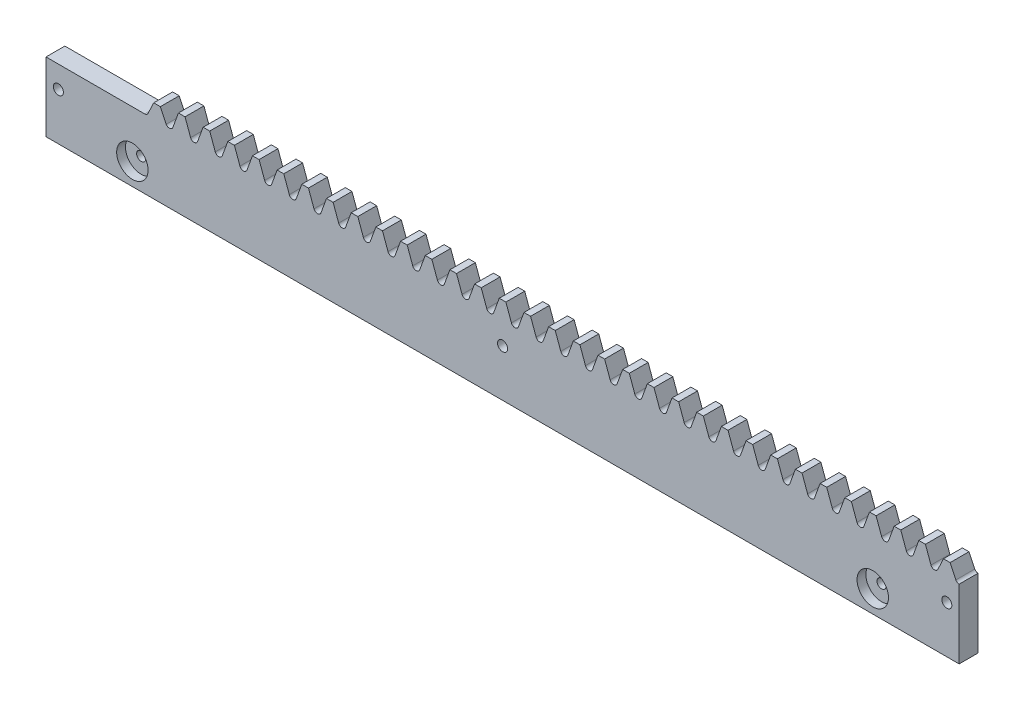
from build123d import *

# Parameters (mm, degrees)
ESQUISSE1_R             = 1.6
EXTRUSION1_DEPTH        = 6
ESQUISSE4_R             = 5
ENL_V_MAT_EXTRU_2_DEPTH = 2.8
ESQUISSE5_R             = 1.45
ENL_V_MAT_EXTRU_3_DEPTH = 2.5


with BuildPart() as part:
    # Esquisse1 → Extrusion1 (new body)
    with BuildSketch(Plane.XY):
        with BuildLine():
            Line((-11.780972452, 22), (19.634954087, 22))
            ThreePointArc((19.634954087, 22), (20.207764851, 22.148388876), (20.636482657, 22.556227657))
            Line((20.636482657, 22.556227657), (22.508375082, 26.5))
            Line((22.508375082, 26.5), (24.615514728, 26.5))
            Line((24.615514728, 26.5), (26.487407153, 22.556227657))
            ThreePointArc((26.487407153, 22.556227657), (26.916124959, 22.148388876), (27.488935722, 22))
            ThreePointArc((27.488935722, 22), (28.165627746, 22.213360175), (28.597563031, 22.776269199))
            Line((28.597563031, 22.776269199), (30.362356717, 27.625))
            Line((30.362356717, 27.625), (32.469496363, 27.625))
            Line((32.469496363, 27.625), (34.234290049, 22.776269199))
            ThreePointArc((34.234290049, 22.776269199), (34.666225334, 22.213360175), (35.342917357, 22))
            ThreePointArc((35.342917357, 22), (36.019609381, 22.213360175), (36.451544666, 22.776269199))
            Line((36.451544666, 22.776269199), (38.216338352, 27.625))
            Line((38.216338352, 27.625), (40.323477998, 27.625))
            Line((40.323477998, 27.625), (42.088271684, 22.776269199))
            ThreePointArc((42.088271684, 22.776269199), (42.520206969, 22.213360175), (43.196898992, 22))
            ThreePointArc((43.196898992, 22), (43.873591016, 22.213360175), (44.305526301, 22.776269199))
            Line((44.305526301, 22.776269199), (46.070319987, 27.625))
            Line((46.070319987, 27.625), (48.177459633, 27.625))
            Line((48.177459633, 27.625), (49.942253319, 22.776269199))
            ThreePointArc((49.942253319, 22.776269199), (50.374188604, 22.213360175), (51.050880627, 22))
            ThreePointArc((51.050880627, 22), (51.727572651, 22.213360175), (52.159507936, 22.776269199))
            Line((52.159507936, 22.776269199), (53.924301622, 27.625))
            Line((53.924301622, 27.625), (56.031441268, 27.625))
            Line((56.031441268, 27.625), (57.796234954, 22.776269199))
            ThreePointArc((57.796234954, 22.776269199), (58.228170239, 22.213360175), (58.904862262, 22))
            ThreePointArc((58.904862262, 22), (59.581554286, 22.213360175), (60.013489571, 22.776269199))
            Line((60.013489571, 22.776269199), (61.778283257, 27.625))
            Line((61.778283257, 27.625), (63.885422903, 27.625))
            Line((63.885422903, 27.625), (65.650216589, 22.776269199))
            ThreePointArc((65.650216589, 22.776269199), (66.082151874, 22.213360175), (66.758843897, 22))
            ThreePointArc((66.758843897, 22), (67.435535921, 22.213360175), (67.867471206, 22.776269199))
            Line((67.867471206, 22.776269199), (69.632264892, 27.625))
            Line((69.632264892, 27.625), (71.739404538, 27.625))
            Line((71.739404538, 27.625), (73.504198224, 22.776269199))
            ThreePointArc((73.504198224, 22.776269199), (73.936133509, 22.213360175), (74.612825532, 22))
            ThreePointArc((74.612825532, 22), (75.289517556, 22.213360175), (75.721452841, 22.776269199))
            Line((75.721452841, 22.776269199), (77.486246527, 27.625))
            Line((77.486246527, 27.625), (79.593386173, 27.625))
            Line((79.593386173, 27.625), (81.358179859, 22.776269199))
            ThreePointArc((81.358179859, 22.776269199), (81.790115144, 22.213360175), (82.466807167, 22))
            ThreePointArc((82.466807167, 22), (83.143499191, 22.213360175), (83.575434476, 22.776269199))
            Line((83.575434476, 22.776269199), (85.340228162, 27.625))
            Line((85.340228162, 27.625), (87.447367808, 27.625))
            Line((87.447367808, 27.625), (89.212161494, 22.776269199))
            ThreePointArc((89.212161494, 22.776269199), (89.644096779, 22.213360175), (90.320788802, 22))
            ThreePointArc((90.320788802, 22), (90.997480826, 22.213360175), (91.429416111, 22.776269199))
            Line((91.429416111, 22.776269199), (93.194209797, 27.625))
            Line((93.194209797, 27.625), (95.301349443, 27.625))
            Line((95.301349443, 27.625), (97.066143129, 22.776269199))
            ThreePointArc((97.066143129, 22.776269199), (97.498078414, 22.213360175), (98.174770437, 22))
            ThreePointArc((98.174770437, 22), (98.851462461, 22.213360175), (99.283397746, 22.776269199))
            Line((99.283397746, 22.776269199), (101.048191432, 27.625))
            Line((101.048191432, 27.625), (103.155331078, 27.625))
            Line((103.155331078, 27.625), (104.920124764, 22.776269199))
            ThreePointArc((104.920124764, 22.776269199), (105.352060049, 22.213360175), (106.028752072, 22))
            ThreePointArc((106.028752072, 22), (106.705444096, 22.213360175), (107.137379381, 22.776269199))
            Line((107.137379381, 22.776269199), (108.902173067, 27.625))
            Line((108.902173067, 27.625), (111.009312713, 27.625))
            Line((111.009312713, 27.625), (112.774106399, 22.776269199))
            ThreePointArc((112.774106399, 22.776269199), (113.206041684, 22.213360175), (113.882733707, 22))
            ThreePointArc((113.882733707, 22), (114.559425731, 22.213360175), (114.991361016, 22.776269199))
            Line((114.991361016, 22.776269199), (116.756154702, 27.625))
            Line((116.756154702, 27.625), (118.863294348, 27.625))
            Line((118.863294348, 27.625), (120.628088034, 22.776269199))
            ThreePointArc((120.628088034, 22.776269199), (121.060023319, 22.213360175), (121.736715342, 22))
            ThreePointArc((121.736715342, 22), (122.413407366, 22.213360175), (122.845342651, 22.776269199))
            Line((122.845342651, 22.776269199), (124.610136337, 27.625))
            Line((124.610136337, 27.625), (126.717275983, 27.625))
            Line((126.717275983, 27.625), (128.482069669, 22.776269199))
            ThreePointArc((128.482069669, 22.776269199), (128.914004954, 22.213360175), (129.590696977, 22))
            ThreePointArc((129.590696977, 22), (130.267389001, 22.213360175), (130.699324286, 22.776269199))
            Line((130.699324286, 22.776269199), (132.464117972, 27.625))
            Line((132.464117972, 27.625), (134.571257618, 27.625))
            Line((134.571257618, 27.625), (136.336051304, 22.776269199))
            ThreePointArc((136.336051304, 22.776269199), (136.767986589, 22.213360175), (137.444678612, 22))
            ThreePointArc((137.444678612, 22), (138.121370636, 22.213360175), (138.553305921, 22.776269199))
            Line((138.553305921, 22.776269199), (140.318099607, 27.625))
            Line((140.318099607, 27.625), (142.425239253, 27.625))
            Line((142.425239253, 27.625), (144.190032939, 22.776269199))
            ThreePointArc((144.190032939, 22.776269199), (144.621968224, 22.213360175), (145.298660247, 22))
            ThreePointArc((145.298660247, 22), (145.975352271, 22.213360175), (146.407287556, 22.776269199))
            Line((146.407287556, 22.776269199), (148.172081242, 27.625))
            Line((148.172081242, 27.625), (150.279220888, 27.625))
            Line((150.279220888, 27.625), (152.044014574, 22.776269199))
            ThreePointArc((152.044014574, 22.776269199), (152.475949859, 22.213360175), (153.152641882, 22))
            ThreePointArc((153.152641882, 22), (153.829333906, 22.213360175), (154.261269191, 22.776269199))
            Line((154.261269191, 22.776269199), (156.026062877, 27.625))
            Line((156.026062877, 27.625), (158.133202523, 27.625))
            Line((158.133202523, 27.625), (159.897996209, 22.776269199))
            ThreePointArc((159.897996209, 22.776269199), (160.329931494, 22.213360175), (161.006623517, 22))
            ThreePointArc((161.006623517, 22), (161.683315541, 22.213360175), (162.115250826, 22.776269199))
            Line((162.115250826, 22.776269199), (163.880044512, 27.625))
            Line((163.880044512, 27.625), (165.987184158, 27.625))
            Line((165.987184158, 27.625), (167.751977844, 22.776269199))
            ThreePointArc((167.751977844, 22.776269199), (168.183913129, 22.213360175), (168.860605152, 22))
            ThreePointArc((168.860605152, 22), (169.537297176, 22.213360175), (169.969232461, 22.776269199))
            Line((169.969232461, 22.776269199), (171.734026147, 27.625))
            Line((171.734026147, 27.625), (173.841165793, 27.625))
            Line((173.841165793, 27.625), (175.605959479, 22.776269199))
            ThreePointArc((175.605959479, 22.776269199), (176.037894764, 22.213360175), (176.714586787, 22))
            ThreePointArc((176.714586787, 22), (177.391278811, 22.213360175), (177.823214096, 22.776269199))
            Line((177.823214096, 22.776269199), (179.588007782, 27.625))
            Line((179.588007782, 27.625), (181.695147428, 27.625))
            Line((181.695147428, 27.625), (183.459941114, 22.776269199))
            ThreePointArc((183.459941114, 22.776269199), (183.891876399, 22.213360175), (184.568568422, 22))
            ThreePointArc((184.568568422, 22), (185.245260446, 22.213360175), (185.677195731, 22.776269199))
            Line((185.677195731, 22.776269199), (187.441989417, 27.625))
            Line((187.441989417, 27.625), (189.549129063, 27.625))
            Line((189.549129063, 27.625), (191.313922749, 22.776269199))
            ThreePointArc((191.313922749, 22.776269199), (191.745858034, 22.213360175), (192.422550057, 22))
            ThreePointArc((192.422550057, 22), (193.099242081, 22.213360175), (193.531177366, 22.776269199))
            Line((193.531177366, 22.776269199), (195.295971052, 27.625))
            Line((195.295971052, 27.625), (197.403110698, 27.625))
            Line((197.403110698, 27.625), (199.167904384, 22.776269199))
            ThreePointArc((199.167904384, 22.776269199), (199.599839669, 22.213360175), (200.276531692, 22))
            ThreePointArc((200.276531692, 22), (200.953223716, 22.213360175), (201.385159001, 22.776269199))
            Line((201.385159001, 22.776269199), (203.149952687, 27.625))
            Line((203.149952687, 27.625), (205.257092333, 27.625))
            Line((205.257092333, 27.625), (207.021886019, 22.776269199))
            ThreePointArc((207.021886019, 22.776269199), (207.453821304, 22.213360175), (208.130513327, 22))
            ThreePointArc((208.130513327, 22), (208.807205351, 22.213360175), (209.239140636, 22.776269199))
            Line((209.239140636, 22.776269199), (211.003934322, 27.625))
            Line((211.003934322, 27.625), (213.111073968, 27.625))
            Line((213.111073968, 27.625), (214.875867654, 22.776269199))
            ThreePointArc((214.875867654, 22.776269199), (215.307802939, 22.213360175), (215.984494962, 22))
            ThreePointArc((215.984494962, 22), (216.661186986, 22.213360175), (217.093122271, 22.776269199))
            Line((217.093122271, 22.776269199), (218.857915957, 27.625))
            Line((218.857915957, 27.625), (220.965055603, 27.625))
            Line((220.965055603, 27.625), (222.729849289, 22.776269199))
            ThreePointArc((222.729849289, 22.776269199), (223.161784574, 22.213360175), (223.838476597, 22))
            ThreePointArc((223.838476597, 22), (224.515168621, 22.213360175), (224.947103906, 22.776269199))
            Line((224.947103906, 22.776269199), (226.711897592, 27.625))
            Line((226.711897592, 27.625), (228.819037238, 27.625))
            Line((228.819037238, 27.625), (230.583830924, 22.776269199))
            ThreePointArc((230.583830924, 22.776269199), (231.015766209, 22.213360175), (231.692458232, 22))
            ThreePointArc((231.692458232, 22), (232.369150256, 22.213360175), (232.801085541, 22.776269199))
            Line((232.801085541, 22.776269199), (234.565879227, 27.625))
            Line((234.565879227, 27.625), (236.673018873, 27.625))
            Line((236.673018873, 27.625), (238.437812559, 22.776269199))
            ThreePointArc((238.437812559, 22.776269199), (238.869747844, 22.213360175), (239.546439867, 22))
            ThreePointArc((239.546439867, 22), (240.223131891, 22.213360175), (240.655067176, 22.776269199))
            Line((240.655067176, 22.776269199), (242.419860862, 27.625))
            Line((242.419860862, 27.625), (244.527000508, 27.625))
            Line((244.527000508, 27.625), (246.291794194, 22.776269199))
            ThreePointArc((246.291794194, 22.776269199), (246.723729479, 22.213360175), (247.400421502, 22))
            ThreePointArc((247.400421502, 22), (248.077113526, 22.213360175), (248.509048811, 22.776269199))
            Line((248.509048811, 22.776269199), (250.273842497, 27.625))
            Line((250.273842497, 27.625), (252.380982143, 27.625))
            Line((252.380982143, 27.625), (254.145775829, 22.776269199))
            ThreePointArc((254.145775829, 22.776269199), (254.577711114, 22.213360175), (255.254403137, 22))
            ThreePointArc((255.254403137, 22), (255.931095161, 22.213360175), (256.363030446, 22.776269199))
            Line((256.363030446, 22.776269199), (258.127824132, 27.625))
            Line((258.127824132, 27.625), (260.234963778, 27.625))
            Line((260.234963778, 27.625), (261.999757464, 22.776269199))
            ThreePointArc((261.999757464, 22.776269199), (262.431692749, 22.213360175), (263.108384772, 22))
            ThreePointArc((263.108384772, 22), (263.785076796, 22.213360175), (264.217012081, 22.776269199))
            Line((264.217012081, 22.776269199), (265.981805767, 27.625))
            Line((265.981805767, 27.625), (268.088945413, 27.625))
            Line((268.088945413, 27.625), (269.853739099, 22.776269199))
            ThreePointArc((269.853739099, 22.776269199), (270.285674384, 22.213360175), (270.962366407, 22))
            ThreePointArc((270.962366407, 22), (271.572652612, 22.17011153), (272.006944946, 22.631389486))
            Line((272.006944946, 22.631389486), (273.835787402, 26.5))
            Line((273.835787402, 26.5), (275.942927048, 26.5))
            Line((275.942927048, 26.5), (277.771769504, 22.631389486))
            ThreePointArc((277.771769504, 22.631389486), (278.206061838, 22.17011153), (278.816348043, 22))
            Line((278.816348043, 22), (278.816348042, 0))
            Line((278.816348042, 0), (-11.780972452, 0))
            Line((-11.780972452, 0), (-11.780972452, 22))
        make_face()
        with Locations((133.517687795, 15)):
            Circle(ESQUISSE1_R, mode=Mode.SUBTRACT)
        with Locations((-7.853981635, 15)):
            Circle(ESQUISSE1_R, mode=Mode.SUBTRACT)
        with Locations((274.889357225, 15)):
            Circle(ESQUISSE1_R, mode=Mode.SUBTRACT)
    extrude(amount=EXTRUSION1_DEPTH)

    # Esquisse4 → Enlèv. mat.-Extru.2 (cut)
    with BuildSketch(Plane.XY.offset(6)):
        with Locations((15.70796327, 7)):
            Circle(ESQUISSE4_R)
        with Locations((251.32741232, 7)):
            Circle(ESQUISSE4_R)
    extrude(amount=-ENL_V_MAT_EXTRU_2_DEPTH, mode=Mode.SUBTRACT)

    # Esquisse5 → Enlèv. mat.-Extru.3 (cut)
    with BuildSketch(Plane.XY.offset(3.2)):
        with Locations((15.70796327, 7)):
            Circle(ESQUISSE5_R)
        with Locations((251.32741232, 7)):
            Circle(ESQUISSE5_R)
    extrude(amount=-ENL_V_MAT_EXTRU_3_DEPTH, mode=Mode.SUBTRACT)


solid = part.part
